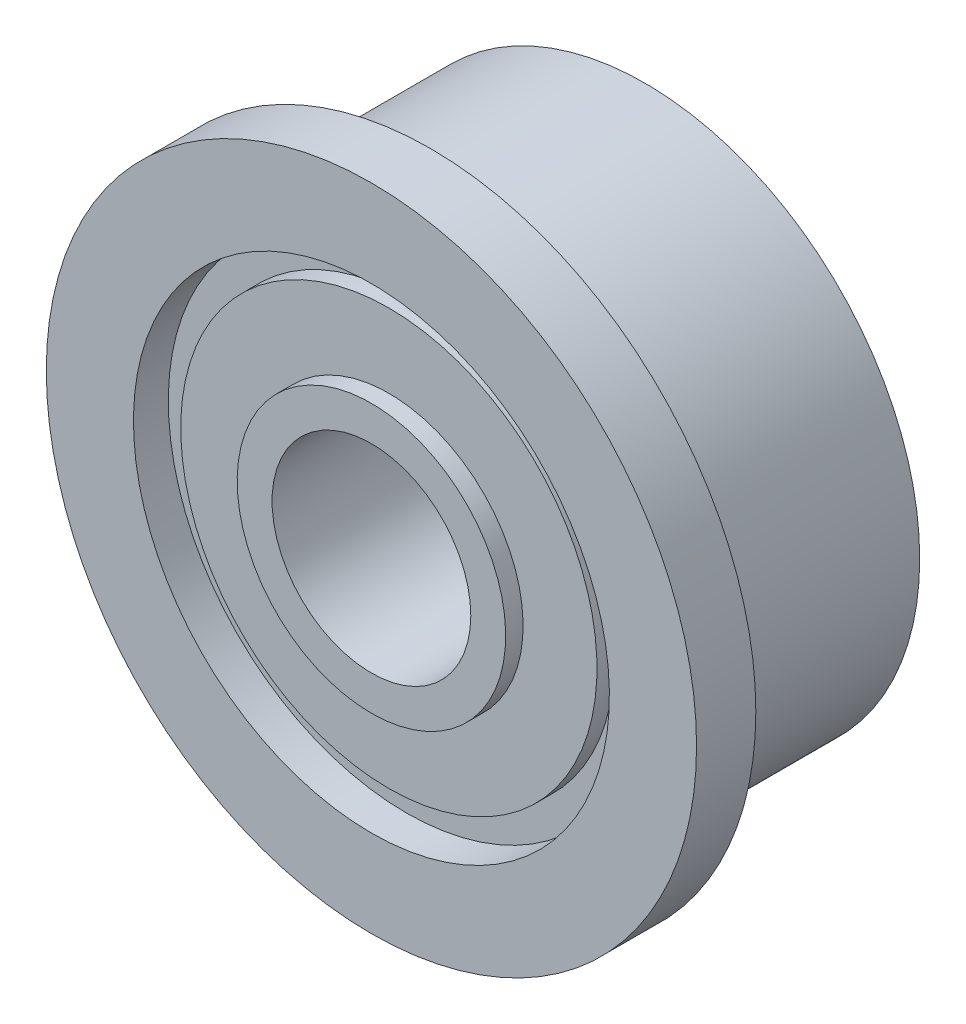
from build123d import *

# Parameters (mm, degrees)
SKETCH2_R      = 1.4478
EXTRUDE1_DEPTH = 4.9878


with BuildPart() as part:
    # Sketch1 → Revolve1 (revolve)
    with BuildSketch(Plane(origin=(0, 0, 0), x_dir=(0, 0, -1), z_dir=(1, 0, 0))):
        Polygon((0, 4.7371), (0, 0), (3.9878, 0), (3.9878, 4.0005), (1.3716, 4.0005), (1.3716, 3.7465), (0.8636, 3.7465), (0.8636, 4.7371), align=None)
    revolve(axis=Axis((0, 0, 0), (0, 0, -1)))

    # Sketch2 → Extrude1 (cut, through all)
    with BuildSketch(Plane.XY):
        Circle(SKETCH2_R)
    extrude(amount=-EXTRUDE1_DEPTH, mode=Mode.SUBTRACT)

    # Sketch3 → Cut-Revolve1 (revolve, cut)
    with BuildSketch(Plane(origin=(0, 0, 0), x_dir=(0, 0, -1), z_dir=(1, 0, 0))):
        Polygon((3.9878, 1.9558), (3.7338, 1.9558), (3.7338, 2.9845), (3.9878, 3.4925), align=None)
        Polygon((0, 1.9558), (0.254, 1.9558), (0.254, 3.032275316), (0.508, 3.032275316), (0.508, 3.4671), (0, 3.4671), align=None)
    revolve(axis=Axis((0, 0, 0), (0, 0, -1)), mode=Mode.SUBTRACT)


solid = part.part
